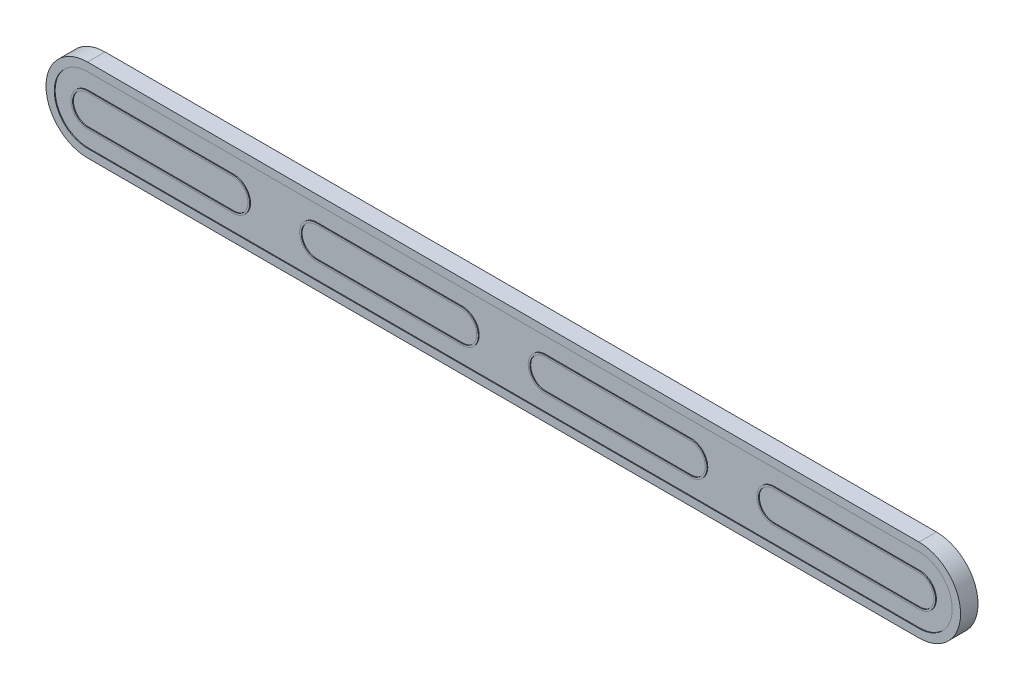
from build123d import *

# Parameters (mm, degrees)
EXTRUDE1_DEPTH = 2
EXTRUDE2_DEPTH = 0.1
EXTRUDE3_DEPTH = 0.1


with BuildPart() as part:
    # Sketch1 → Extrude1 (new body)
    with BuildSketch(Plane.XY):
        with BuildLine():
            Line((-50, 5), (50, 5))
            ThreePointArc((50, 5), (55, 0), (50, -5))
            Line((50, -5), (-50, -5))
            ThreePointArc((-50, -5), (-55, 0), (-50, 5))
        make_face()
    extrude(amount=EXTRUDE1_DEPTH)

    # Sketch2 → Extrude2 (add)
    with BuildSketch(Plane.XY.offset(2)):
        with BuildLine():
            Line((-50, 5), (50, 5))
            ThreePointArc((50, 5), (55, 0), (50, -5))
            Line((50, -5), (-50, -5))
            ThreePointArc((-50, -5), (-55, 0), (-50, 5))
        make_face()
        with BuildLine():
            Line((-50, 4), (50, 4))
            ThreePointArc((50, 4), (54, 0), (50, -4))
            Line((50, -4), (-50, -4))
            ThreePointArc((-50, -4), (-54, 0), (-50, 4))
        make_face(mode=Mode.SUBTRACT)
    extrude(amount=EXTRUDE2_DEPTH)

    # Sketch3 → Extrude3 (add)
    with BuildSketch(Plane.XY.offset(2)):
        with BuildLine():
            Line((-49.999999498, 2), (-32.499999623, 2))
            ThreePointArc((-32.499999623, 2), (-30.499999623, 0), (-32.499999623, -2))
            Line((-32.499999623, -2), (-49.999999498, -2))
            ThreePointArc((-49.999999498, -2), (-51.999999498, 0), (-49.999999498, 2))
        make_face()
        with BuildLine():
            Line((-50, 1.8), (-32.499999623, 1.8))
            ThreePointArc((-32.499999623, 1.8), (-30.699999623, 0), (-32.499999623, -1.8))
            Line((-32.499999623, -1.8), (-50, -1.8))
            ThreePointArc((-50, -1.8), (-51.8, 0), (-50, 1.8))
        make_face(mode=Mode.SUBTRACT)
        with BuildLine():
            Line((-22.499999623, 2), (-4.999999749, 2))
            ThreePointArc((-4.999999749, 2), (-2.999999749, 0), (-4.999999749, -2))
            Line((-4.999999749, -2), (-22.499999623, -2))
            ThreePointArc((-22.499999623, -2), (-24.499999623, 0), (-22.499999623, 2))
        make_face()
        with BuildLine():
            Line((-22.499999623, 1.8), (-4.999999749, 1.8))
            ThreePointArc((-4.999999749, 1.8), (-3.199999749, 0), (-4.999999749, -1.8))
            Line((-4.999999749, -1.8), (-22.499999623, -1.8))
            ThreePointArc((-22.499999623, -1.8), (-24.299999623, 0), (-22.499999623, 1.8))
        make_face(mode=Mode.SUBTRACT)
        with BuildLine():
            Line((5.000000251, 2), (22.500000126, 2))
            ThreePointArc((22.500000126, 2), (24.500000126, 0), (22.500000126, -2))
            Line((22.500000126, -2), (5.000000251, -2))
            ThreePointArc((5.000000251, -2), (3.000000251, 0), (5.000000251, 2))
        make_face()
        with BuildLine():
            Line((5.000000251, 1.8), (22.500000126, 1.8))
            ThreePointArc((22.500000126, 1.8), (24.300000126, 0), (22.500000126, -1.8))
            Line((22.500000126, -1.8), (5.000000251, -1.8))
            ThreePointArc((5.000000251, -1.8), (3.200000251, 0), (5.000000251, 1.8))
        make_face(mode=Mode.SUBTRACT)
        with BuildLine():
            Line((32.500000126, 2), (50, 2))
            ThreePointArc((50, 2), (52, 0), (50, -2))
            Line((50, -2), (32.500000126, -2))
            ThreePointArc((32.500000126, -2), (30.500000126, 0), (32.500000126, 2))
        make_face()
        with BuildLine():
            Line((32.500000126, 1.8), (50, 1.8))
            ThreePointArc((50, 1.8), (51.8, 0), (50, -1.8))
            Line((50, -1.8), (32.500000126, -1.8))
            ThreePointArc((32.500000126, -1.8), (30.700000126, 0), (32.500000126, 1.8))
        make_face(mode=Mode.SUBTRACT)
    extrude(amount=EXTRUDE3_DEPTH)


solid = part.part
